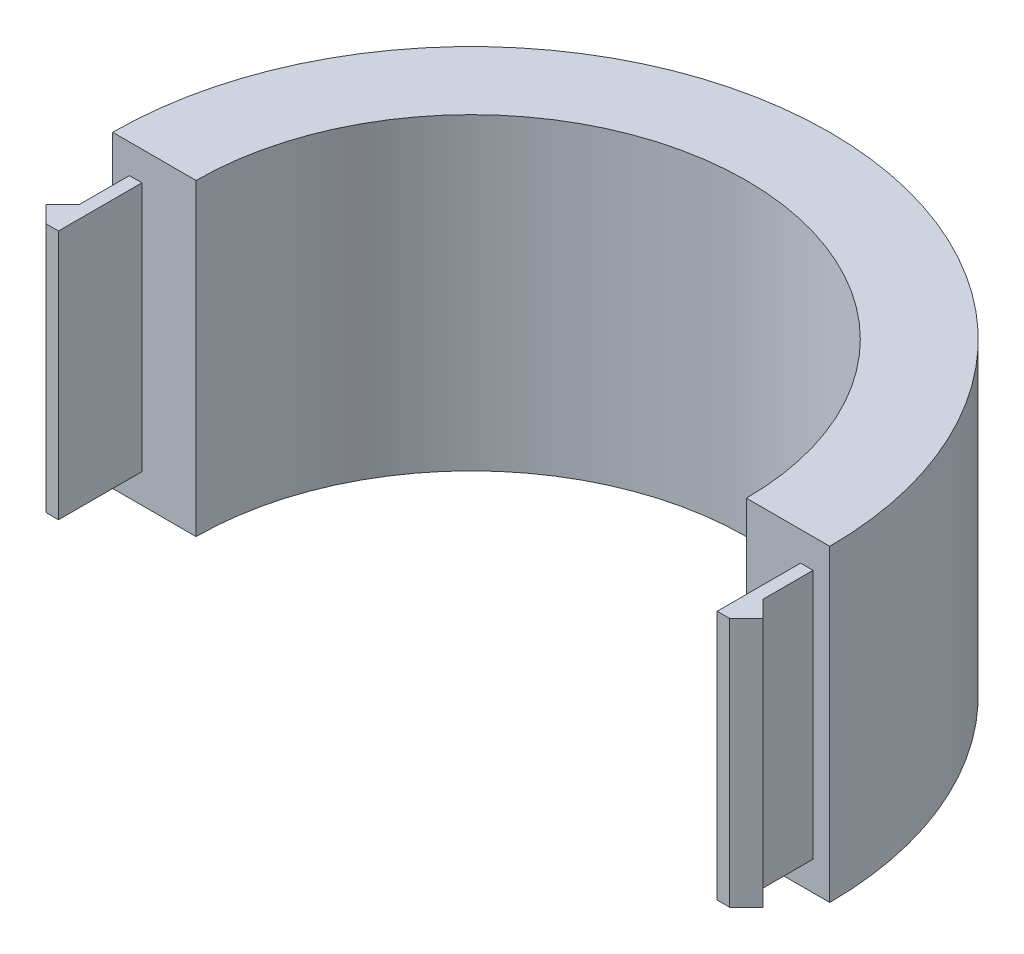
from build123d import *

# Parameters (mm, degrees)
BOSS_EXTRUDE1_DEPTH = 37
SKETCH3_W           = 1.5
SKETCH3_H           = 10
BOSS_EXTRUDE2_DEPTH = 15


with BuildPart() as part:
    # Sketch1 → Boss-Extrude1 (new body)
    with BuildSketch(Plane(origin=(0, 0, 0), x_dir=(1, 0, 0), z_dir=(0, 1, 0))):
        with BuildLine():
            ThreePointArc((-33, 0), (0, 33), (33, 0))
            Line((33, 0), (43, 0))
            ThreePointArc((43, 0), (0, 43), (-43, 0))
            Line((-43, 0), (-33, 0))
        make_face()
    extrude(amount=BOSS_EXTRUDE1_DEPTH)

    # Sketch3 → Boss-Extrude2 (add, symmetric)
    with BuildSketch(Plane(origin=(0, 18.5, 0), x_dir=(1, 0, 0), z_dir=(0, 1, 0))):
        with Locations((-40.25, -5)):
            Rectangle(SKETCH3_W, SKETCH3_H)
        Polygon((-43, -8), (-41, -10), (-41, -6), align=None)
    boss_extrude2 = extrude(amount=BOSS_EXTRUDE2_DEPTH, both=True)

    # Mirror1: Boss-Extrude2 across plane
    add(boss_extrude2.mirror(Plane(origin=(0, 0, 0), x_dir=(0, 0, 1), z_dir=(1, 0, 0))))


solid = part.part
